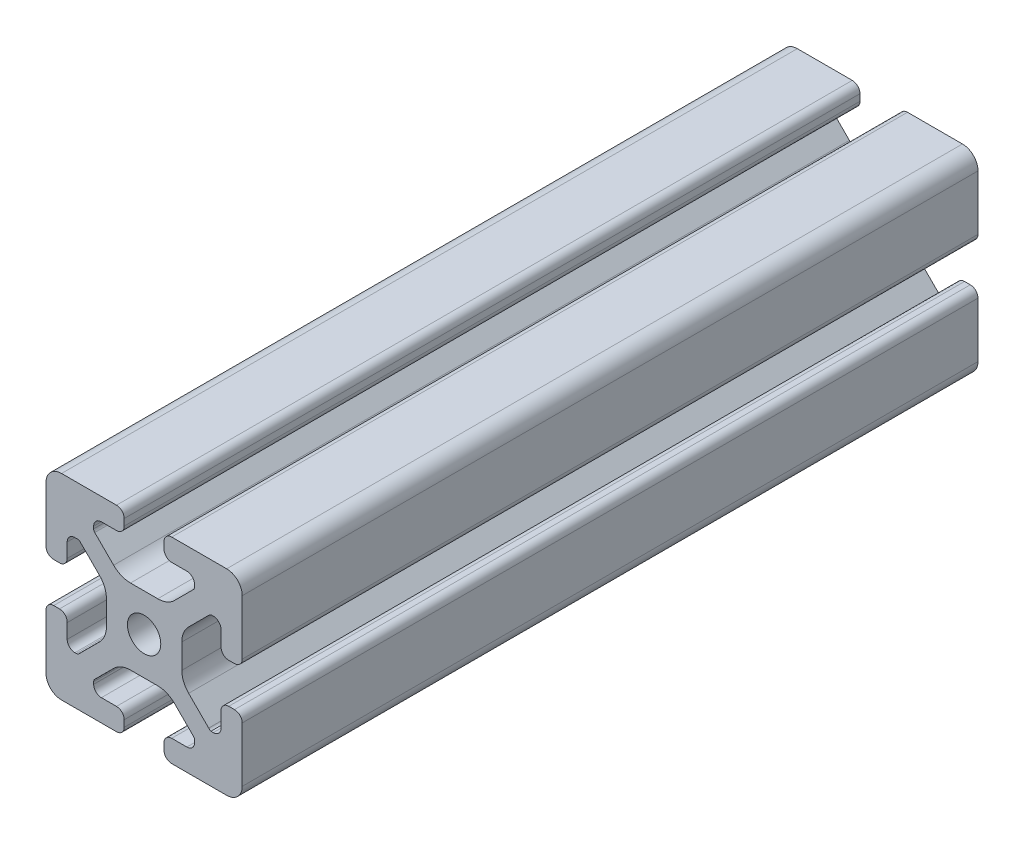
from build123d import *

# Parameters (mm, degrees)
SKETCH1_R      = 3.4
EXTRUDE1_DEPTH = 150


with BuildPart() as part:
    # Sketch1 → Extrude1 (new body)
    with BuildSketch(Plane.XY):
        with BuildLine():
            Line((-8.715, -15.524615034), (-5.63, -15.524615034))
            ThreePointArc((-5.63, -15.524615034), (-4.519842354, -15.984457388), (-4.06, -17.094615034))
            Line((-4.06, -17.094615034), (-4.06, -18.43))
            ThreePointArc((-4.06, -18.43), (-4.519842354, -19.540157646), (-5.63, -20))
            Line((-5.63, -20), (-16.674615034, -20))
            ThreePointArc((-16.674615034, -20), (-18.951578385, -19.194274381), (-20, -17.018368134))
            Line((-20, -17.018368134), (-20, -5.757918808))
            ThreePointArc((-20, -5.757918808), (-19.564709668, -4.603883664), (-18.43, -4.120449326))
            Line((-18.43, -4.120449326), (-17.25, -4.120449326))
            ThreePointArc((-17.25, -4.120449326), (-16.115287682, -4.60388249), (-15.67999625, -5.757919334))
            Line((-15.67999625, -5.757919334), (-15.67999625, -8.715399492))
            ThreePointArc((-15.67999625, -8.715399492), (-15.220153896, -9.825557139), (-14.10999625, -10.285399492))
            Line((-14.10999625, -10.285399492), (-13.816898819, -10.285399492))
            ThreePointArc((-13.816898819, -10.285399492), (-13.526061711, -10.227547119), (-13.279501941, -10.062800646))
            Line((-13.279501941, -10.062800646), (-9.076242789, -5.859541495))
            ThreePointArc((-9.076242789, -5.859541495), (-8.046572221, -4.318530588), (-7.685, -2.500784284))
            Line((-7.685, -2.500784284), (-7.685, 2.500784284))
            ThreePointArc((-7.685, 2.500784284), (-8.046572221, 4.318530588), (-9.076242789, 5.859541495))
            Line((-9.076242789, 5.859541495), (-13.040489136, 9.823787841))
            ThreePointArc((-13.040489136, 9.823787841), (-13.354224618, 10.012729352), (-13.71989919, 10.033001362))
            Line((-13.71989919, 10.033001362), (-14.05520779, 10.044710596))
            ThreePointArc((-14.05520779, 10.044710596), (-15.200613642, 9.605030484), (-15.68, 8.475666998))
            Line((-15.68, 8.475666998), (-15.68, 5.572979049))
            ThreePointArc((-15.68, 5.572979049), (-16.139842354, 4.462821403), (-17.25, 4.002979049))
            Line((-17.25, 4.002979049), (-18.43, 4.002979049))
            ThreePointArc((-18.43, 4.002979049), (-19.540157646, 4.462821403), (-20, 5.572979049))
            Line((-20, 5.572979049), (-20, 13.004526564))
            Line((-20, 13.004526564), (-20, 16.83))
            ThreePointArc((-20, 16.83), (-19.071528496, 19.071528496), (-16.83, 20))
            Line((-16.83, 20), (-5.63, 20))
            ThreePointArc((-5.63, 20), (-4.519842354, 19.540157646), (-4.06, 18.43))
            Line((-4.06, 18.43), (-4.06, 17.094615034))
            ThreePointArc((-4.06, 17.094615034), (-4.519842354, 15.984457388), (-5.63, 15.524615034))
            Line((-5.63, 15.524615034), (-8.715, 15.524615034))
            ThreePointArc((-8.715, 15.524615034), (-9.825157646, 15.06477268), (-10.285, 13.954615034))
            Line((-10.285, 13.954615034), (-10.285, 13.492503602))
            ThreePointArc((-10.285, 13.492503602), (-10.227148445, 13.201664194), (-10.062401154, 12.955102448))
            Line((-10.062401154, 12.955102448), (-6.217092793, 9.109794088))
            ThreePointArc((-6.217092793, 9.109794088), (-4.63891877, 8.055291919), (-2.777335583, 7.685))
            Line((-2.777335583, 7.685), (2.777335583, 7.685))
            ThreePointArc((2.777335583, 7.685), (4.63891877, 8.055291919), (6.217092793, 9.109794088))
            Line((6.217092793, 9.109794088), (10.062401154, 12.955102448))
            ThreePointArc((10.062401154, 12.955102448), (10.227148445, 13.201664194), (10.285, 13.492503602))
            Line((10.285, 13.492503602), (10.285, 13.954615034))
            ThreePointArc((10.285, 13.954615034), (9.825157646, 15.06477268), (8.715, 15.524615034))
            Line((8.715, 15.524615034), (5.63, 15.524615034))
            ThreePointArc((5.63, 15.524615034), (4.519842354, 15.984457388), (4.06, 17.094615034))
            Line((4.06, 17.094615034), (4.06, 18.43))
            ThreePointArc((4.06, 18.43), (4.519842354, 19.540157646), (5.63, 20))
            Line((5.63, 20), (12.979635074, 20))
            Line((12.979635074, 20), (16.83, 20))
            ThreePointArc((16.83, 20), (19.071528496, 19.071528496), (20, 16.83))
            Line((20, 16.83), (20, 13.001098436))
            Line((20, 13.001098436), (20, 5.63))
            ThreePointArc((20, 5.63), (19.540157461, 4.519842693), (18.43, 4.060000526))
            Line((18.43, 4.060000526), (17.24999625, 4.060000526))
            ThreePointArc((17.24999625, 4.060000526), (16.139838603, 4.519842879), (15.67999625, 5.630000526))
            Line((15.67999625, 5.630000526), (15.67999625, 8.715399492))
            ThreePointArc((15.67999625, 8.715399492), (15.220153896, 9.825557139), (14.10999625, 10.285399492))
            Line((14.10999625, 10.285399492), (13.816903094, 10.285399492))
            ThreePointArc((13.816903094, 10.285399492), (13.526063686, 10.227547937), (13.279501941, 10.062800646))
            Line((13.279501941, 10.062800646), (9.076242789, 5.859541495))
            ThreePointArc((9.076242789, 5.859541495), (8.046572221, 4.318530588), (7.685, 2.500784284))
            Line((7.685, 2.500784284), (7.685, -2.500784284))
            ThreePointArc((7.685, -2.500784284), (8.046572221, -4.318530588), (9.076242789, -5.859541495))
            Line((9.076242789, -5.859541495), (13.163657296, -9.946956002))
            ThreePointArc((13.163657296, -9.946956002), (13.35903797, -10.160433474), (13.6200547, -10.285399492))
            Line((13.6200547, -10.285399492), (14.10999625, -10.285399492))
            ThreePointArc((14.10999625, -10.285399492), (15.220153896, -9.825557139), (15.67999625, -8.715399492))
            Line((15.67999625, -8.715399492), (15.67999625, -5.630000526))
            ThreePointArc((15.67999625, -5.630000526), (16.139838603, -4.519842879), (17.24999625, -4.060000526))
            Line((17.24999625, -4.060000526), (18.43, -4.060000526))
            ThreePointArc((18.43, -4.060000526), (19.540157461, -4.519842693), (20, -5.63))
            Line((20, -5.63), (20, -16.83))
            ThreePointArc((20, -16.83), (19.071528496, -19.071528496), (16.83, -20))
            Line((16.83, -20), (13, -20))
            Line((13, -20), (5.63, -20))
            ThreePointArc((5.63, -20), (4.519842354, -19.540157646), (4.06, -18.43))
            Line((4.06, -18.43), (4.06, -17.094615034))
            ThreePointArc((4.06, -17.094615034), (4.519842354, -15.984457388), (5.63, -15.524615034))
            Line((5.63, -15.524615034), (8.715, -15.524615034))
            ThreePointArc((8.715, -15.524615034), (9.825157646, -15.06477268), (10.285, -13.954615034))
            Line((10.285, -13.954615034), (10.285, -13.492503602))
            ThreePointArc((10.285, -13.492503602), (10.227148445, -13.201664194), (10.062401154, -12.955102448))
            Line((10.062401154, -12.955102448), (6.217092793, -9.109794088))
            ThreePointArc((6.217092793, -9.109794088), (4.63891877, -8.055291919), (2.777335583, -7.685))
            Line((2.777335583, -7.685), (-2.777335583, -7.685))
            ThreePointArc((-2.777335583, -7.685), (-4.63891877, -8.055291919), (-6.217092793, -9.109794088))
            Line((-6.217092793, -9.109794088), (-10.062401154, -12.955102448))
            ThreePointArc((-10.062401154, -12.955102448), (-10.227148445, -13.201664194), (-10.285, -13.492503602))
            Line((-10.285, -13.492503602), (-10.285, -13.954615034))
            ThreePointArc((-10.285, -13.954615034), (-9.825157646, -15.06477268), (-8.715, -15.524615034))
        make_face()
        Circle(SKETCH1_R, mode=Mode.SUBTRACT)
    extrude(amount=-EXTRUDE1_DEPTH)


solid = part.part
